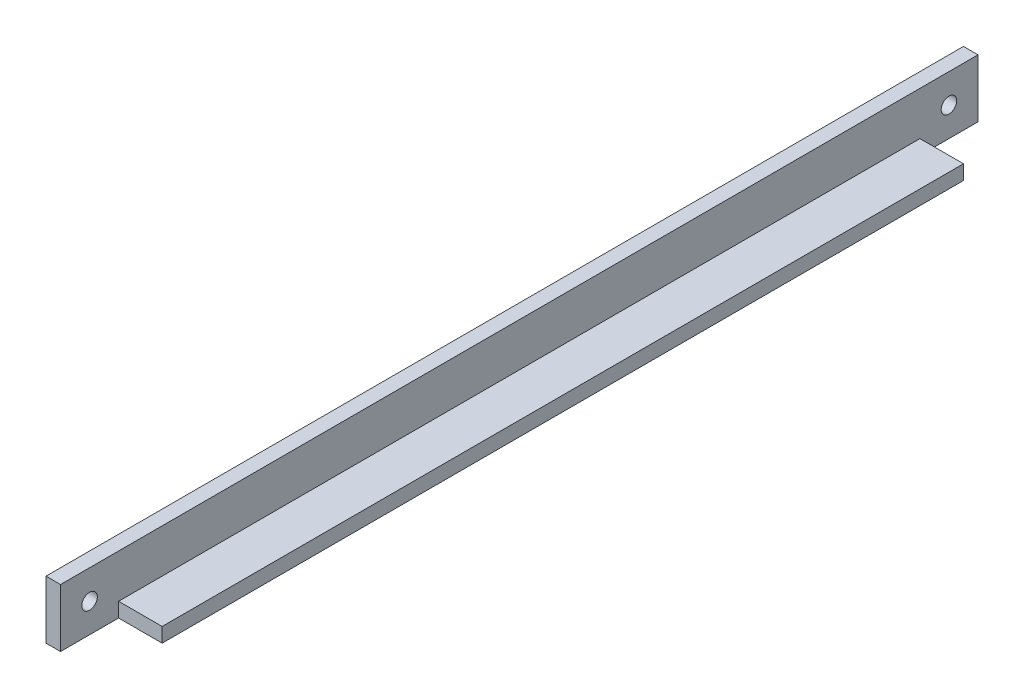
from build123d import *

# Parameters (mm, degrees)
BOSS_EXTRUDE1_DEPTH  = 200.66
SKETCH2_W            = 9.525
SKETCH2_H            = 12.7
CUT_EXTRUDE1_DEPTH   = 4.175
M3_CLEARANCE_HOLE1_D = 3.4


with BuildPart() as part:
    # Sketch1 → Boss-Extrude1 (new body)
    with BuildSketch(Plane.XY):
        Polygon((0, 0), (0, 12.7), (3.175, 12.7), (3.175, 3.175), (12.7, 3.175), (12.7, 0), align=None)
    extrude(amount=BOSS_EXTRUDE1_DEPTH)

    # Sketch2 → Cut-Extrude1 (cut, through all)
    with BuildSketch(Plane(origin=(0, 3.175, 0), x_dir=(1, 0, 0), z_dir=(0, 1, 0))):
        with Locations((7.9375, -6.35)):
            Rectangle(SKETCH2_W, SKETCH2_H)
        with Locations((7.9375, -194.31)):
            Rectangle(SKETCH2_W, SKETCH2_H)
    extrude(amount=-CUT_EXTRUDE1_DEPTH, mode=Mode.SUBTRACT)

    # M3 Clearance Hole1 (through all)
    with Locations(Plane(origin=(0, 6.35, 6.35), x_dir=(0, 0, -1), z_dir=(-1, 0, 0))):
        with Locations((0, 0), (-187.96, 0)):
            Hole(M3_CLEARANCE_HOLE1_D / 2)


solid = part.part
